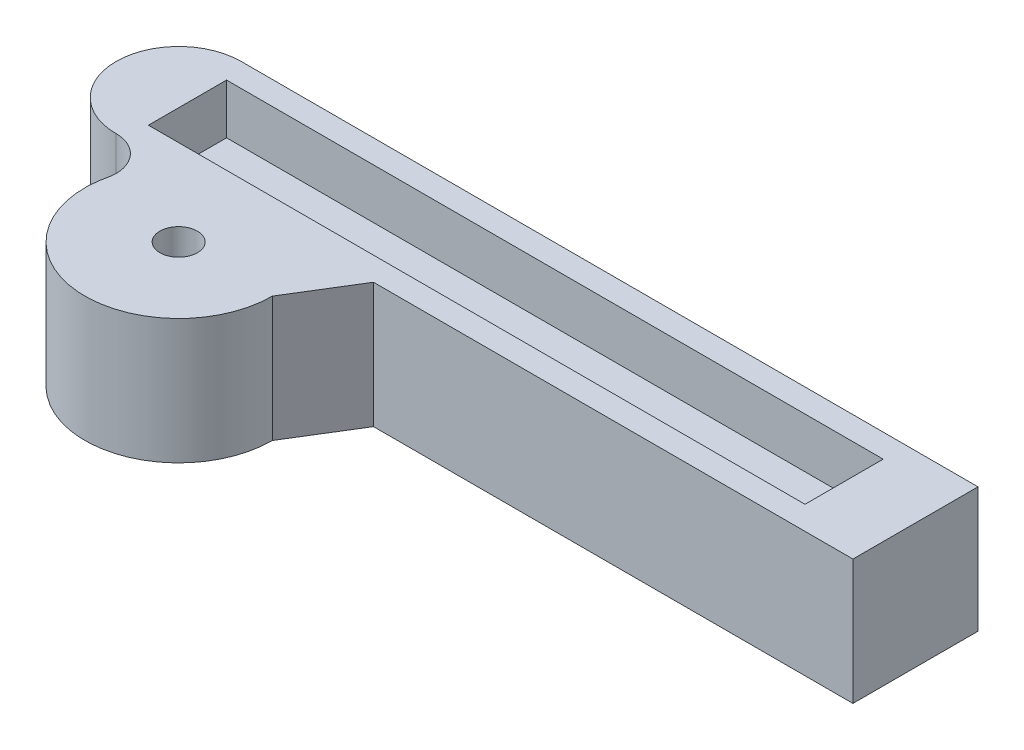
from build123d import *

# Parameters (mm, degrees)
SKETCH1_R           = 3
BOSS_EXTRUDE1_DEPTH = 20
SKETCH8_W           = 105
SKETCH8_H           = 12.5
CUT_EXTRUDE7_DEPTH  = 8
SKETCH9_W           = 105
SKETCH9_H           = 12.5
CUT_EXTRUDE8_DEPTH  = 8


with BuildPart() as part:
    # Sketch1 → Boss-Extrude1 (new body)
    with BuildSketch(Plane(origin=(0, 0, 0), x_dir=(1, 0, 0), z_dir=(0, 1, 0))):
        with BuildLine():
            Line((-20, 30), (97.83, 30))
            Line((97.83, 30), (97.83, 10))
            Line((97.83, 10), (21.160500507, 10))
            Line((21.160500507, 10), (15, 0))
            ThreePointArc((15, 0), (-1.903014387, -14.878794852), (-14.517138166, 3.775274755))
            ThreePointArc((-14.517138166, 3.775274755), (-15.852441132, 8.126182851), (-20, 10))
            ThreePointArc((-20, 10), (-30, 20), (-20, 30))
        make_face()
        Circle(SKETCH1_R, mode=Mode.SUBTRACT)
    extrude(amount=BOSS_EXTRUDE1_DEPTH)

    # Sketch8 → Cut-Extrude7 (cut)
    with BuildSketch(Plane.XZ):
        with Locations((33.915, -20.25)):
            Rectangle(SKETCH8_W, SKETCH8_H)
    extrude(amount=-CUT_EXTRUDE7_DEPTH, mode=Mode.SUBTRACT)

    # Sketch9 → Cut-Extrude8 (cut)
    with BuildSketch(Plane(origin=(0, 20, 0), x_dir=(1, 0, 0), z_dir=(0, 1, 0))):
        with Locations((33.915, 20)):
            Rectangle(SKETCH9_W, SKETCH9_H)
    extrude(amount=-CUT_EXTRUDE8_DEPTH, mode=Mode.SUBTRACT)


solid = part.part
